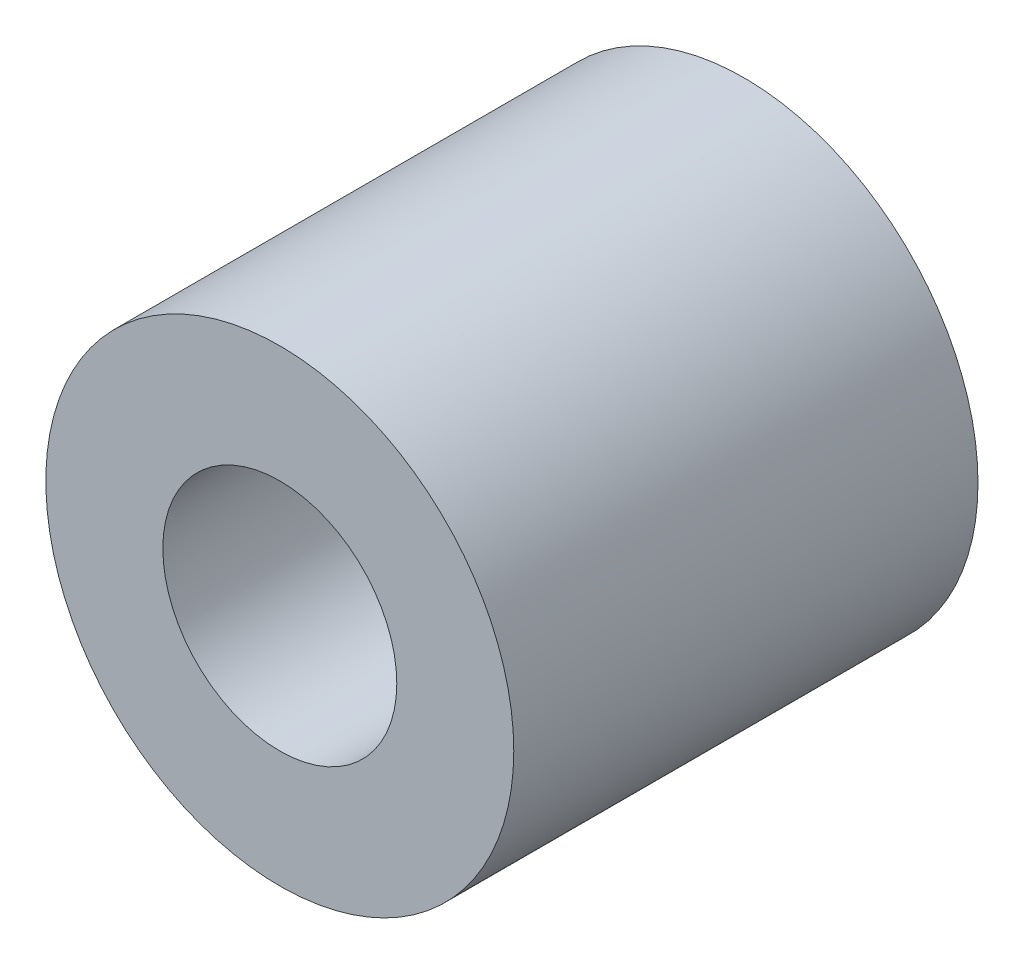
from build123d import *

# Parameters (mm, degrees)
SKETCH1_R      = 3.2004
SKETCH1_R_2    = 1.6002
EXTRUDE1_DEPTH = 3.175


with BuildPart() as part:
    # Sketch1 → Extrude1 (new body, symmetric)
    with BuildSketch(Plane.XY):
        Circle(SKETCH1_R)
        Circle(SKETCH1_R_2, mode=Mode.SUBTRACT)
    extrude(amount=EXTRUDE1_DEPTH, both=True)


solid = part.part
